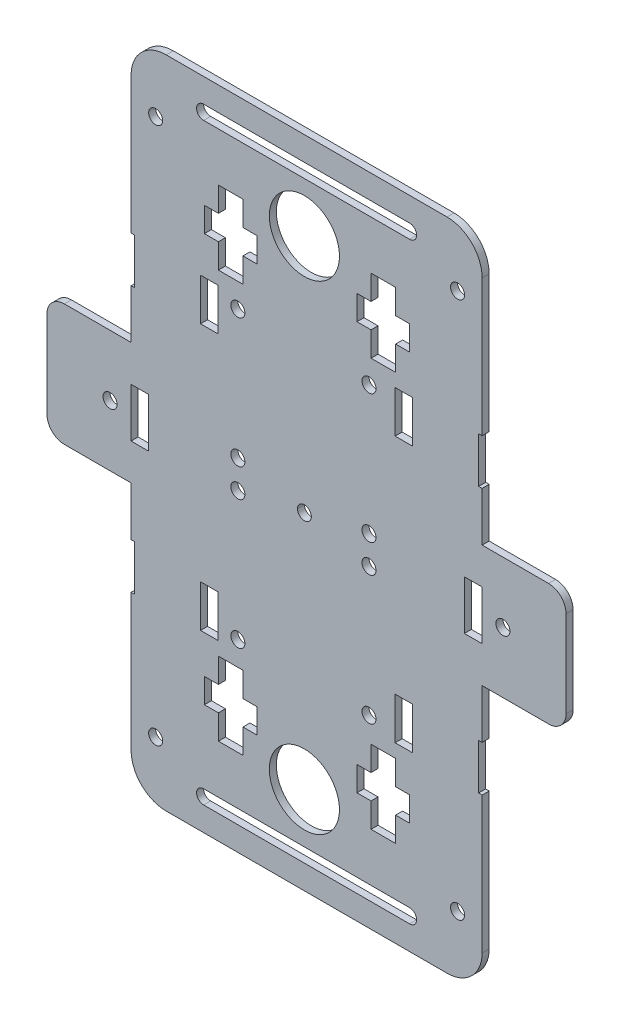
from build123d import *

# Parameters (mm, degrees)
SKETCH1_R           = 10
SKETCH1_R_2         = 1.972602619
BOSS_EXTRUDE2_DEPTH = 2
SKETCH5_W           = 5
SKETCH5_H           = 14
CUT_EXTRUDE3_DEPTH  = 3.0000001
SKETCH6_W           = 5
SKETCH6_H           = 14
CUT_EXTRUDE4_DEPTH  = 3.0000001
SKETCH19_R          = 2
CUT_EXTRUDE19_DEPTH = 3.0000001
SKETCH22_R          = 2
CUT_EXTRUDE22_DEPTH = 3.0000001
SKETCH23_R          = 2
CUT_EXTRUDE23_DEPTH = 3.0000001
SKETCH24_R          = 2
CUT_EXTRUDE24_DEPTH = 3.0000001
SKETCH25_W          = 5
SKETCH25_H          = 12
CUT_EXTRUDE25_DEPTH = 3.0000001
CUT_EXTRUDE26_DEPTH = 3.0000001
CUT_EXTRUDE29_DEPTH = 3.0000001
SKETCH20_R          = 2
CUT_EXTRUDE20_DEPTH = 3.0000001
SKETCH30_W          = 181.696441894
SKETCH30_H          = 131.456906608
CUT_EXTRUDE30_DEPTH = 3
SKETCH31_R          = 2
CUT_EXTRUDE31_DEPTH = 2
SKETCH32_W          = 167.461823271
SKETCH32_H          = 37.26795508
CUT_EXTRUDE32_DEPTH = 2
FILLET1_R           = 10
FILLET2_R           = 5


with BuildPart() as part:
    # Sketch1 → Boss-Extrude2 (new body)
    with BuildSketch(Plane.XY):
        with BuildLine():
            Line((-49.4, 97.775402254), (-49.4, 48.775402254))
            Line((-49.4, 48.775402254), (-48.4, 48.775402254))
            Line((-48.4, 48.775402254), (-48.4, 35.775402254))
            Line((-48.4, 35.775402254), (-49.4, 35.775402254))
            Line((-49.4, 35.775402254), (-49.4, 21.775402254))
            Line((-49.4, 21.775402254), (-73.4, 21.775402254))
            Line((-73.4, 21.775402254), (-73.4, -12.924597746))
            Line((-73.4, -12.924597746), (-49.4, -12.924597746))
            Line((-49.4, -12.924597746), (-49.4, -26.924597746))
            Line((-49.4, -26.924597746), (-48.4, -26.924597746))
            Line((-48.4, -26.924597746), (-48.4, -39.924597746))
            Line((-48.4, -39.924597746), (-49.4, -39.924597746))
            Line((-49.4, -39.924597746), (-49.4, -88.924597746))
            Line((-49.4, -88.924597746), (-73.349457369, -88.924597746))
            add(Edge.make_bspline(
                [(-73.349457369, -88.924597746), (-70.502213021, -123.490651401), (3.447241601, -123.490651401), (77.396696223, -123.490651401), (74.549451875, -88.924597746)],
                knots=[3.190793702, 3.190793702, 3.190793702, 4.761590029, 4.761590029, 6.332386355, 6.332386355, 6.332386355], degree=2, weights=[1, 0.707106781, 1, 0.707106781, 1]))
            Line((74.549451875, -88.924597746), (50.599994505, -88.924597746))
            Line((50.599994505, -88.924597746), (50.599994505, -39.924597746))
            Line((50.599994505, -39.924597746), (49.599994505, -39.924597746))
            Line((49.599994505, -39.924597746), (49.599994505, -26.924597746))
            Line((49.599994505, -26.924597746), (50.599994505, -26.924597746))
            Line((50.599994505, -26.924597746), (50.599994505, -12.924597746))
            Line((50.599994505, -12.924597746), (74.599994505, -12.924597746))
            Line((74.599994505, -12.924597746), (74.599994505, 21.775402254))
            Line((74.599994505, 21.775402254), (50.669116659, 21.775402254))
            Line((50.669116659, 21.775402254), (50.669116659, 35.775402254))
            Line((50.669116659, 35.775402254), (49.669116659, 35.775402254))
            Line((49.669116659, 35.775402254), (49.669116659, 48.775402254))
            Line((49.669116659, 48.775402254), (50.669116659, 48.775402254))
            Line((50.669116659, 48.775402254), (50.669116659, 97.775402254))
            Line((50.669116659, 97.775402254), (74.669116659, 97.775402254))
            add(Edge.make_bspline(
                [(74.669116659, 97.775402254), (74.669116659, 132.775402254), (0.587265356, 132.775402254), (-73.494585946, 132.775402254), (-73.494585946, 97.775402254)],
                knots=[3.141592654, 3.141592654, 3.141592654, 4.71238898, 4.71238898, 6.283185307, 6.283185307, 6.283185307], degree=2, weights=[1, 0.707106781, 1, 0.707106781, 1]))
            Line((-73.494585946, 97.775402254), (-49.4, 97.775402254))
        make_face()
        with Locations((0, 72.732378713)):
            Circle(SKETCH1_R, mode=Mode.SUBTRACT)
        with Locations((0, -63.883577786)):
            Circle(SKETCH1_R, mode=Mode.SUBTRACT)
        with Locations((0, 4.424400463)):
            Circle(SKETCH1_R_2, mode=Mode.SUBTRACT)
    extrude(amount=BOSS_EXTRUDE2_DEPTH)

    # Sketch5 → Cut-Extrude3 (cut, through all)
    with BuildSketch(Plane(origin=(0, 0, 0), x_dir=(-1, 0, 0), z_dir=(0, 0, -1))):
        with Locations((46.9, 4.425402254)):
            Rectangle(SKETCH5_W, SKETCH5_H)
    extrude(amount=-CUT_EXTRUDE3_DEPTH, mode=Mode.SUBTRACT)

    # Sketch6 → Cut-Extrude4 (cut, through all)
    with BuildSketch(Plane(origin=(0, 0, 0), x_dir=(-1, 0, 0), z_dir=(0, 0, -1))):
        with Locations((-48.099994505, 4.425402254)):
            Rectangle(SKETCH6_W, SKETCH6_H)
    extrude(amount=-CUT_EXTRUDE4_DEPTH, mode=Mode.SUBTRACT)

    # Sketch19 → Cut-Extrude19 (cut, through all)
    with BuildSketch(Plane(origin=(0, 0, 0), x_dir=(-1, 0, 0), z_dir=(0, 0, -1))):
        with Locations((-56.599994505, 4.425402254)):
            Circle(SKETCH19_R)
    extrude(amount=-CUT_EXTRUDE19_DEPTH, mode=Mode.SUBTRACT)

    # Sketch22 → Cut-Extrude22 (cut, through all)
    with BuildSketch(Plane(origin=(0, 0, 0), x_dir=(-1, 0, 0), z_dir=(0, 0, -1))):
        with Locations((42.4, 81)):
            Circle(SKETCH22_R)
        with Locations((-43.669116659, 81)):
            Circle(SKETCH22_R)
    extrude(amount=-CUT_EXTRUDE22_DEPTH, mode=Mode.SUBTRACT)

    # Sketch23 → Cut-Extrude23 (cut, through all)
    with BuildSketch(Plane.XY.offset(2)):
        with Locations((43.599994505, -81)):
            Circle(SKETCH23_R)
        with Locations((-42.4, -81)):
            Circle(SKETCH23_R)
    extrude(amount=-CUT_EXTRUDE23_DEPTH, mode=Mode.SUBTRACT)

    # Sketch24 → Cut-Extrude24 (cut, through all)
    with BuildSketch(Plane.XY.offset(2)):
        with Locations((-50, -94.924597746)):
            Circle(SKETCH24_R)
        with Locations((50, -94.924597746)):
            Circle(SKETCH24_R)
        with Locations((-50, 103.775402254)):
            Circle(SKETCH24_R)
        with Locations((50, 103.775402254)):
            Circle(SKETCH24_R)
    extrude(amount=-CUT_EXTRUDE24_DEPTH, mode=Mode.SUBTRACT)

    # Sketch25 → Cut-Extrude25 (cut, through all)
    with BuildSketch(Plane(origin=(0, 0, 0), x_dir=(-1, 0, 0), z_dir=(0, 0, -1))):
        with Locations((-28.369116659, 42.275402254)):
            Rectangle(SKETCH25_W, SKETCH25_H)
        with Locations((27.1, 42.275402254)):
            Rectangle(SKETCH25_W, SKETCH25_H)
        with Locations((-28.299994505, -33.424597746)):
            Rectangle(SKETCH25_W, SKETCH25_H)
        with Locations((27.1, -33.424597746)):
            Rectangle(SKETCH25_W, SKETCH25_H)
    extrude(amount=-CUT_EXTRUDE25_DEPTH, mode=Mode.SUBTRACT)

    # Sketch26 → Cut-Extrude26 (cut, through all)
    with BuildSketch(Plane(origin=(0, 0, 0), x_dir=(-1, 0, 0), z_dir=(0, 0, -1))):
        Polygon((24.510151311, 52.075402254), (17.510151311, 52.075402254), (17.510151311, 59.075402254), (13.510151311, 59.075402254), (13.510151311, 66.075402254), (17.510151311, 66.075402254), (17.510151311, 73.075402254), (24.510151311, 73.075402254), (24.510151311, 66.075402254), (28.510151311, 66.075402254), (28.510151311, 59.075402254), (24.510151311, 59.075402254), align=None)
        Polygon((-29.999116659, 59.075402254), (-29.999116659, 66.075402254), (-25.999116659, 66.075402254), (-25.999116659, 73.075402254), (-18.999116659, 73.075402254), (-18.999116659, 66.075402254), (-14.999116659, 66.075402254), (-14.999116659, 59.075402254), (-18.999116659, 59.075402254), (-18.999116659, 52.075402254), (-25.999116659, 52.075402254), (-25.999116659, 59.075402254), align=None)
        Polygon((-19, -69), (-19, -62), (-15, -62), (-15, -55), (-19, -55), (-19, -48), (-26, -48), (-26, -55), (-30, -55), (-30, -62), (-26, -62), (-26, -69), align=None)
        Polygon((24.510151311, -48), (17.510151311, -48), (17.510151311, -55), (13.510151311, -55), (13.510151311, -62), (17.510151311, -62), (17.510151311, -69), (24.510151311, -69), (24.510151311, -62), (28.510151311, -62), (28.510151311, -55), (24.510151311, -55), align=None)
    extrude(amount=-CUT_EXTRUDE26_DEPTH, mode=Mode.SUBTRACT)

    # Sketch28 → Cut-Extrude29 (cut, through all)
    with BuildSketch(Plane(origin=(0, 0, 0), x_dir=(-1, 0, 0), z_dir=(0, 0, -1))):
        with BuildLine():
            Line((28.730883341, 86.928533544), (-30, 86.928533544))
            ThreePointArc((-30, 86.928533544), (-32, 88.928533544), (-30, 90.928533544))
            Line((-30, 90.928533544), (28.730883341, 90.928533544))
            ThreePointArc((28.730883341, 90.928533544), (30.730883341, 88.928533544), (28.730883341, 86.928533544))
        make_face()
    extrude(amount=-CUT_EXTRUDE29_DEPTH, mode=Mode.SUBTRACT)

    # Sketch20 → Cut-Extrude20 (cut, through all)
    with BuildSketch(Plane(origin=(0, 0, 0), x_dir=(-1, 0, 0), z_dir=(0, 0, -1))):
        with Locations((55.4, 4.425402254)):
            Circle(SKETCH20_R)
    extrude(amount=-CUT_EXTRUDE20_DEPTH, mode=Mode.SUBTRACT)

    # Sketch30 → Cut-Extrude30 (cut)
    with BuildSketch(Plane(origin=(0, 0, 0), x_dir=(-1, 0, 0), z_dir=(0, 0, -1))):
        with Locations((-2.534318945, -61.30305105)):
            Rectangle(SKETCH30_W, SKETCH30_H)
    extrude(amount=-CUT_EXTRUDE30_DEPTH, mode=Mode.SUBTRACT)

    # Sketch31 → Cut-Extrude31 (cut)
    with BuildSketch(Plane(origin=(0, 0, 0), x_dir=(-1, 0, 0), z_dir=(0, 0, -1))):
        with Locations((-18.412976441, 45.21289193)):
            Circle(SKETCH31_R)
        with Locations((-18.413659383, 8.47289193)):
            Circle(SKETCH31_R)
        with Locations((18.967023559, 45.21289193)):
            Circle(SKETCH31_R)
        with Locations((18.966340617, 8.47289193)):
            Circle(SKETCH31_R)
    extrude(amount=-CUT_EXTRUDE31_DEPTH, mode=Mode.SUBTRACT)

    # Sketch32 → Cut-Extrude32 (cut)
    with BuildSketch(Plane(origin=(0, 0, 0), x_dir=(-1, 0, 0), z_dir=(0, 0, -1))):
        with Locations((-4.661465148, 116.409379794)):
            Rectangle(SKETCH32_W, SKETCH32_H)
    extrude(amount=-CUT_EXTRUDE32_DEPTH, mode=Mode.SUBTRACT)

    # Fillet1
    fillet1_edges = [part.edges().sort_by_distance(p)[0] for p in [
        (-49.4, 97.775402254, 1),
        (50.669116659, 97.775402254, 1),
    ]]
    fillet(fillet1_edges, radius=FILLET1_R)

    # Fillet2
    fillet2_edges = [part.edges().sort_by_distance(p)[0] for p in [
        (74.599994505, 21.775402254, 1),
        (-73.4, 21.775402254, 1),
    ]]
    fillet(fillet2_edges, radius=FILLET2_R)

    # Mirror1: part across plane


with BuildPart() as part_1:
    add(part.part)
    add(part.part.mirror(Plane(origin=(0, 4.425402254, 0), x_dir=(0, 0, 1), z_dir=(0, -1, 0))))


solid = part_1.part
